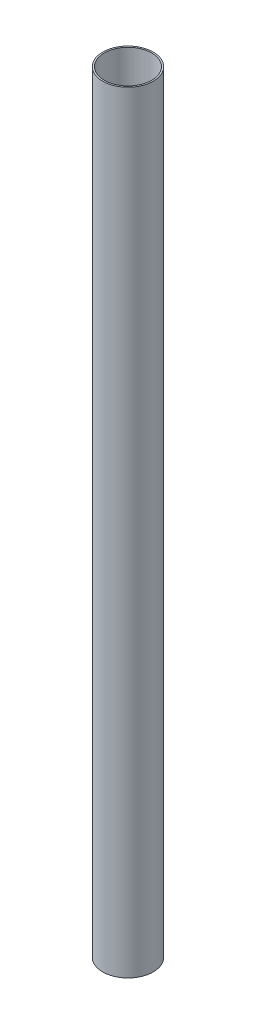
from build123d import *

# Parameters (mm, degrees)
SKETCH1_R           = 29.1084
SKETCH1_R_2         = 27.3304
BOSS_EXTRUDE1_DEPTH = 888.746


with BuildPart() as part:
    # Sketch1 → Boss-Extrude1 (new body)
    with BuildSketch(Plane(origin=(0, 0, 0), x_dir=(1, 0, 0), z_dir=(0, 1, 0))):
        Circle(SKETCH1_R)
        Circle(SKETCH1_R_2, mode=Mode.SUBTRACT)
    extrude(amount=BOSS_EXTRUDE1_DEPTH)


solid = part.part
